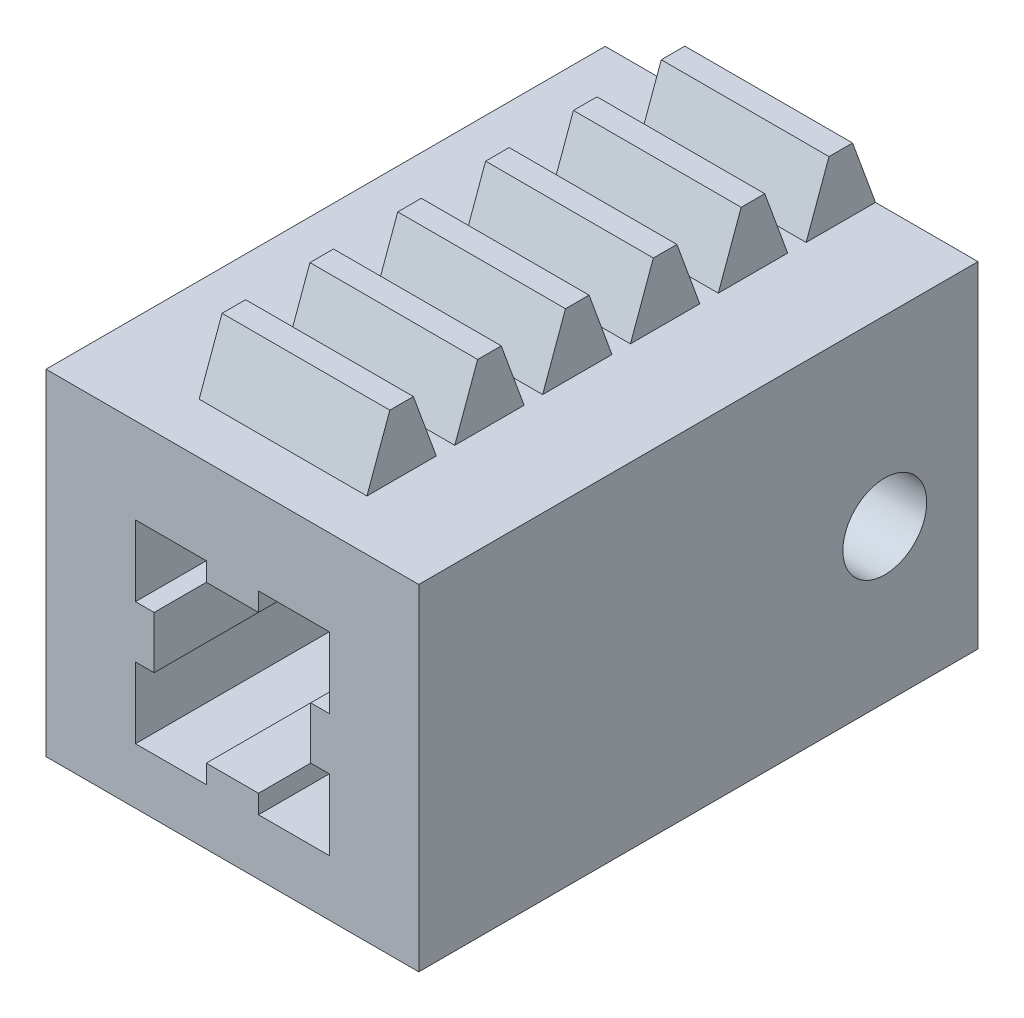
from build123d import *

# Parameters (mm, degrees)
ESQUISSE1_W                = 20
ESQUISSE1_H                = 18
MAIN_EXTRUSION_DEPTH       = 30
MAIN_RIDING_HOLE_DEPTH     = 31
ESQUISSE4_R                = 2.25
TRACTORHOLE_DEPTH          = 8
BOSS_EXTRU_1_DEPTH         = 4.5
R_P_TITION_LIN_AIRE1_COUNT = 6
R_P_TITION_LIN_AIRE1_PITCH = 4.71238898


with BuildPart() as part:
    # Esquisse1 → Main Extrusion (new body)
    with BuildSketch(Plane.XY):
        Rectangle(ESQUISSE1_W, ESQUISSE1_H)
    extrude(amount=MAIN_EXTRUSION_DEPTH)

    # Esquisse3 → Main Riding Hole (cut, through all)
    with BuildSketch(Plane(origin=(0, 0, 0), x_dir=(-1, 0, 0), z_dir=(0, 0, -1))):
        Polygon((-5.2, 4.4), (-5.2, 0.6), (-4.2, 0.6), (-4.2, -2.2), (-5.2, -2.2), (-5.2, -6), (-1.4, -6), (-1.4, -5), (1.4, -5), (1.4, -6), (5.2, -6), (5.2, -2.2), (4.2, -2.2), (4.2, 0.6), (5.2, 0.6), (5.2, 4.4), (1.4, 4.4), (1.4, 3.4), (-1.4, 3.4), (-1.4, 4.4), align=None)
    extrude(amount=-MAIN_RIDING_HOLE_DEPTH, mode=Mode.SUBTRACT)

    # Esquisse4 → TractorHole (cut)
    with BuildSketch(Plane.ZY.offset(10)):
        with Locations((5, -0.8)):
            Circle(ESQUISSE4_R)
    tractorhole = extrude(amount=-TRACTORHOLE_DEPTH, mode=Mode.SUBTRACT)

    # TractorHoleSymetry: TractorHole across plane
    add(tractorhole.mirror(Plane(origin=(0, 0, 0), x_dir=(0, 0, 1), z_dir=(1, 0, 0))), mode=Mode.SUBTRACT)

    # Esquisse8 → Boss.-Extru.1 (add, symmetric)
    with BuildSketch(Plane(origin=(0, 0, 0), x_dir=(0, 0, -1), z_dir=(1, 0, 0))):
        Polygon((-3.721082869, 9), (-2.492683328, 12.375), (-1.228399541, 12.375), (0, 9), align=None)
    boss_extru_1 = extrude(amount=BOSS_EXTRU_1_DEPTH, both=True)

    # Répétition linéaire1: Boss.-Extru.1 ×6
    with Locations(*[(0, 0, i * R_P_TITION_LIN_AIRE1_PITCH) for i in range(1, R_P_TITION_LIN_AIRE1_COUNT)]):
        add(boss_extru_1)


solid = part.part
